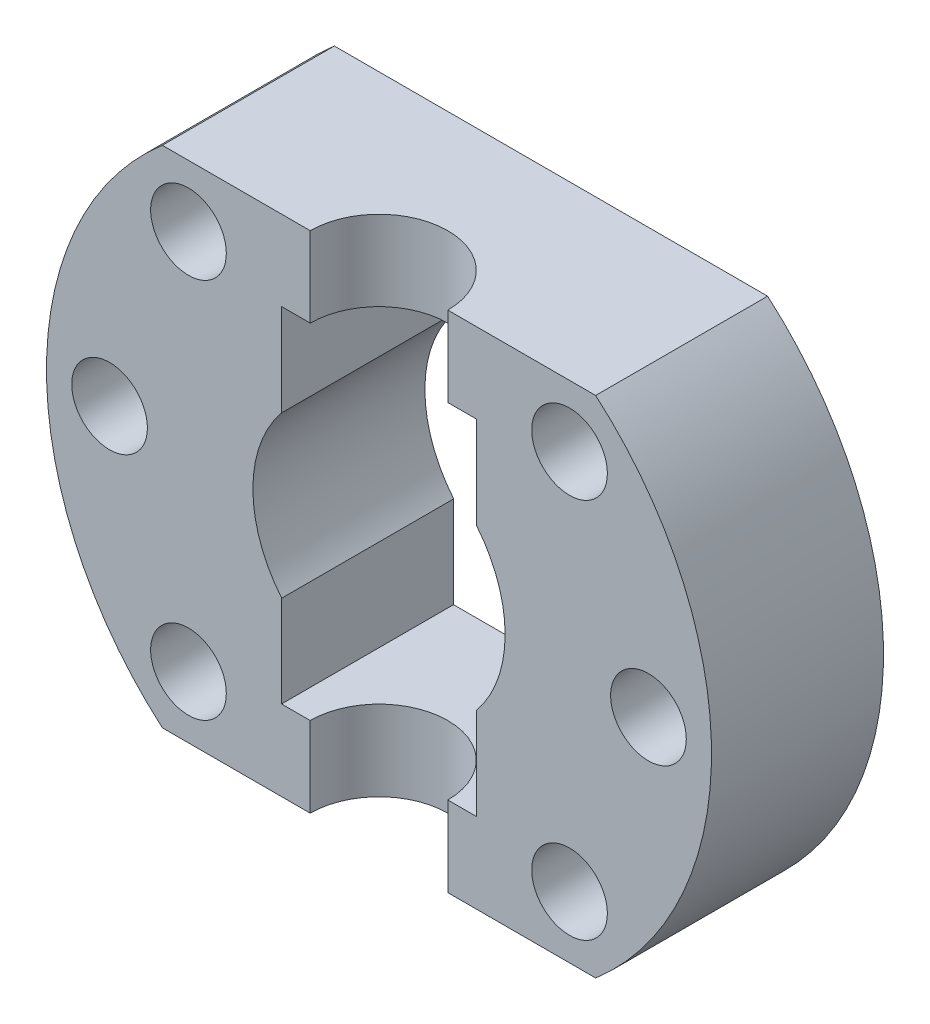
from build123d import *

# Parameters (mm, degrees)
SZKIC1_R                    = 3.3
SZKIC1_R_2                  = 11
DODANIE_WYCI_GNI_CIE2_DEPTH = 15
SZKIC2_W                    = 17
SZKIC2_H                    = 8
SZKIC2_H_2                  = 8.035759956
WYTNIJ_WYCI_GNI_CIE1_DEPTH  = 16
SZKIC3_R                    = 6
WYTNIJ_WYCI_GNI_CIE2_DEPTH  = 45


with BuildPart() as part:
    # Szkic1 → Dodanie-wyciągnięcie2 (new body)
    with BuildSketch(Plane.XY):
        with BuildLine():
            Line((-18.894443628, 22), (18.894443628, 22))
            ThreePointArc((18.894443628, 22), (29, 0), (18.894443628, -22))
            Line((18.894443628, -22), (-18.894443628, -22))
            ThreePointArc((-18.894443628, -22), (-29, 0), (-18.894443628, 22))
        make_face()
        with Locations((-23.5, 0)):
            Circle(SZKIC1_R, mode=Mode.SUBTRACT)
        with Locations((-16.617009358, 16.617009358)):
            Circle(SZKIC1_R, mode=Mode.SUBTRACT)
        with Locations((16.617009358, 16.617009358)):
            Circle(SZKIC1_R, mode=Mode.SUBTRACT)
        with Locations((23.5, 0)):
            Circle(SZKIC1_R, mode=Mode.SUBTRACT)
        with Locations((16.617009358, -16.617009358)):
            Circle(SZKIC1_R, mode=Mode.SUBTRACT)
        with Locations((-16.617009358, -16.617009358)):
            Circle(SZKIC1_R, mode=Mode.SUBTRACT)
        Circle(SZKIC1_R_2, mode=Mode.SUBTRACT)
    extrude(amount=DODANIE_WYCI_GNI_CIE2_DEPTH)

    # Szkic2 → Wytnij-wyciągnięcie1 (cut, through all)
    with BuildSketch(Plane.XY.offset(15)):
        with Locations((0, -11)):
            Rectangle(SZKIC2_W, SZKIC2_H)
        with Locations((0, 11)):
            Rectangle(SZKIC2_W, SZKIC2_H_2)
    extrude(amount=-WYTNIJ_WYCI_GNI_CIE1_DEPTH, mode=Mode.SUBTRACT)

    # Szkic3 → Wytnij-wyciągnięcie2 (cut, through all)
    with BuildSketch(Plane.XZ.offset(22)):
        with Locations((0, 15)):
            Circle(SZKIC3_R)
    extrude(amount=-WYTNIJ_WYCI_GNI_CIE2_DEPTH, mode=Mode.SUBTRACT)


solid = part.part
